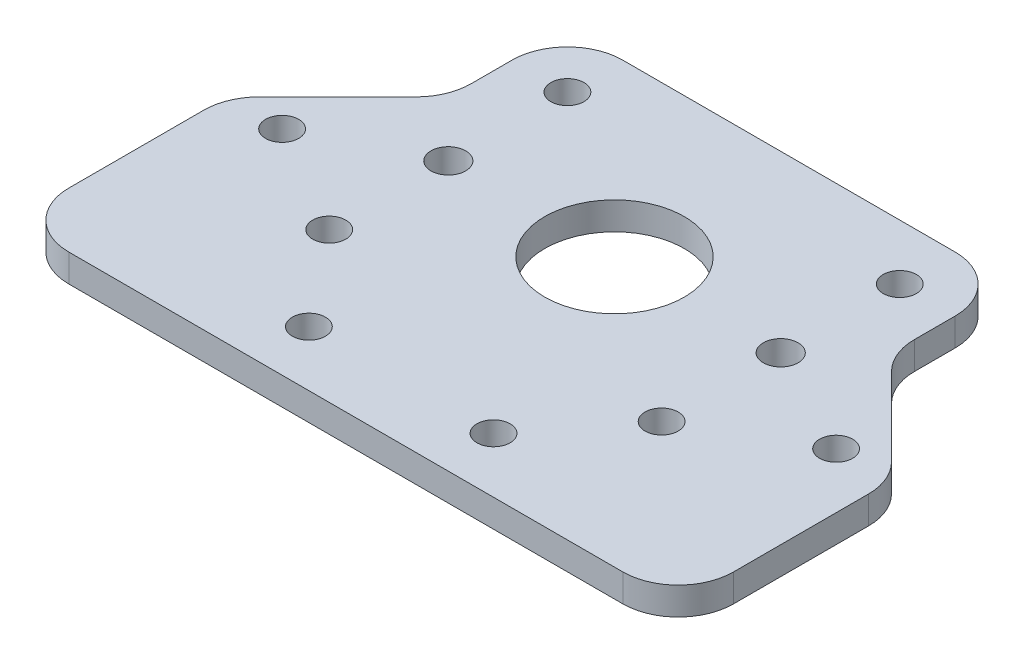
from build123d import *

# Parameters (mm, degrees)
SKETCH1_R           = 8
BOSS_EXTRUDE1_DEPTH = 3.175
SKETCH2_R           = 1.9939
CUT_EXTRUDE1_DEPTH  = 4.175
SKETCH14_R          = 1.89865
M3_TAP_DEPTH        = 4.175
SKETCH15_R          = 1.89865
M5_THROUGH_DEPTH    = 4.175
CUT_EXTRUDE2_DEPTH  = 4.175
FILLET2_R           = 6.35


with BuildPart() as part:
    # Sketch1 → Boss-Extrude1 (new body)
    with BuildSketch(Plane(origin=(0, 0, 0), x_dir=(1, 0, 0), z_dir=(0, 1, 0))):
        Polygon((0, 0), (76.2, 0), (76.2, 50.8), (38.1, 50.8), (0, 50.8), align=None)
        with Locations((38.1, 30.8)):
            Circle(SKETCH1_R, mode=Mode.SUBTRACT)
    extrude(amount=BOSS_EXTRUDE1_DEPTH)

    # Sketch2 → Cut-Extrude1 (cut, through all)
    with BuildSketch(Plane(origin=(0, 3.175, 0), x_dir=(1, 0, 0), z_dir=(0, 1, 0))):
        with Locations((19.05, 30.8)):
            Circle(SKETCH2_R)
        with Locations((57.15, 30.8)):
            Circle(SKETCH2_R)
    extrude(amount=-CUT_EXTRUDE1_DEPTH, mode=Mode.SUBTRACT)

    # Sketch14 → M3-tap (cut, through all)
    with BuildSketch(Plane.XZ):
        with Locations((57.15, -44.45)):
            Circle(SKETCH14_R)
        with Locations((19.05, -44.45)):
            Circle(SKETCH14_R)
        with Locations((19.05, -17.15)):
            Circle(SKETCH14_R)
        with Locations((57.15, -17.15)):
            Circle(SKETCH14_R)
    extrude(amount=-M3_TAP_DEPTH, mode=Mode.SUBTRACT)

    # Sketch15 → M5-through (cut, through all)
    with BuildSketch(Plane.XZ):
        with Locations((69.85, -24.45004)):
            Circle(SKETCH15_R)
        with Locations((48.683333333, -6.35)):
            Circle(SKETCH15_R)
        with Locations((27.516666667, -6.35)):
            Circle(SKETCH15_R)
        with Locations((6.35, -24.45004)):
            Circle(SKETCH15_R)
    extrude(amount=-M5_THROUGH_DEPTH, mode=Mode.SUBTRACT)

    # Sketch12 → Cut-Extrude2 (cut, through all)
    with BuildSketch(Plane(origin=(0, 3.175, 0), x_dir=(1, 0, 0), z_dir=(0, 1, 0))):
        Polygon((0, 50.8), (12.7, 50.8), (12.7, 37.15), (0, 24.45), align=None)
        Polygon((63.5, 50.8), (63.5, 37.15), (76.2, 24.45), (76.2, 50.8), align=None)
    extrude(amount=-CUT_EXTRUDE2_DEPTH, mode=Mode.SUBTRACT)

    # Fillet2
    fillet2_edges = [part.edges().sort_by_distance(p)[0] for p in [
        (0, 1.5875, -24.45),
        (12.7, 1.5875, -50.8),
        (12.7, 1.5875, -37.15),
        (63.5, 1.5875, -50.8),
        (76.2, 1.5875, -24.45),
        (63.5, 1.5875, -37.15),
        (76.2, 1.5875, 0),
        (0, 1.5875, 0),
    ]]
    fillet(fillet2_edges, radius=FILLET2_R)


solid = part.part
